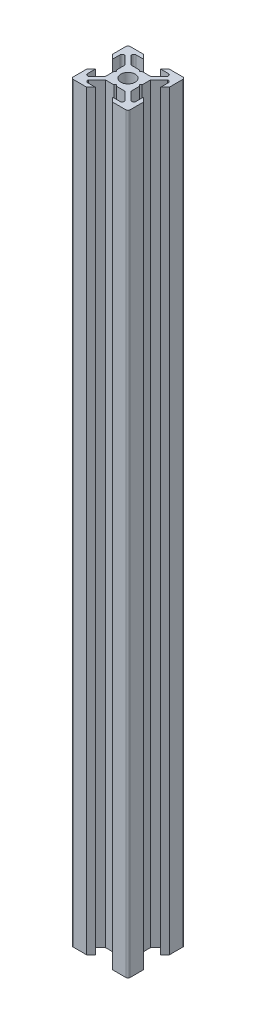
from build123d import *

# Parameters (mm, degrees)
ESQUISSE1_R      = 2.5
EXTRUSION1_DEPTH = 264
CONG_1_R         = 0.75


with BuildPart() as part:
    # Esquisse1 → Extrusion1 (new body)
    with BuildSketch(Plane(origin=(0, 0, 0), x_dir=(1, 0, 0), z_dir=(0, 1, 0))):
        Polygon((0, 4), (-0.5, 4.5), (-3.439339828, 4.5), (-6.439339828, 7.5), (-6.439339828, 8.5), (-3, 8.5), (-4.5, 10), (-10, 10), (-10, 4.5), (-8.5, 3), (-8.5, 6.439339828), (-7.5, 6.439339828), (-4.5, 3.439339828), (-4.5, 0.5), (-4, 0), (-4.5, -0.5), (-4.5, -3.439339828), (-7.5, -6.439339828), (-8.5, -6.439339828), (-8.5, -3), (-10, -4.5), (-10, -10), (-4.5, -10), (-3, -8.5), (-6.439339828, -8.5), (-6.439339828, -7.5), (-3.439339828, -4.5), (-0.5, -4.5), (0, -4), (0.5, -4.5), (3.439339828, -4.5), (6.439339828, -7.5), (6.439339828, -8.5), (3, -8.5), (4.5, -10), (10, -10), (10, -4.5), (8.5, -3), (8.5, -6.439339828), (7.5, -6.439339828), (4.5, -3.439339828), (4.5, -0.5), (4, 0), (4.5, 0.5), (4.5, 3.439339828), (7.5, 6.439339828), (8.5, 6.439339828), (8.5, 3), (10, 4.5), (10, 10), (4.5, 10), (3, 8.5), (6.439339828, 8.5), (6.439339828, 7.5), (3.439339828, 4.5), (0.5, 4.5), align=None)
        Circle(ESQUISSE1_R, mode=Mode.SUBTRACT)
    extrude(amount=EXTRUSION1_DEPTH)

    # Congé1
    cong_1_edges = [part.edges().sort_by_distance(p)[0] for p in [
        (6.439339828, 132, -8.5),
        (10, 132, -10),
        (8.5, 132, -6.439339828),
        (8.5, 132, 6.439339828),
        (10, 132, 10),
        (6.439339828, 132, 8.5),
        (-6.439339828, 132, 8.5),
        (-10, 132, 10),
        (-8.5, 132, 6.439339828),
        (-8.5, 132, -6.439339828),
        (-10, 132, -10),
        (-6.439339828, 132, -8.5),
    ]]
    fillet(cong_1_edges, radius=CONG_1_R)


solid = part.part
